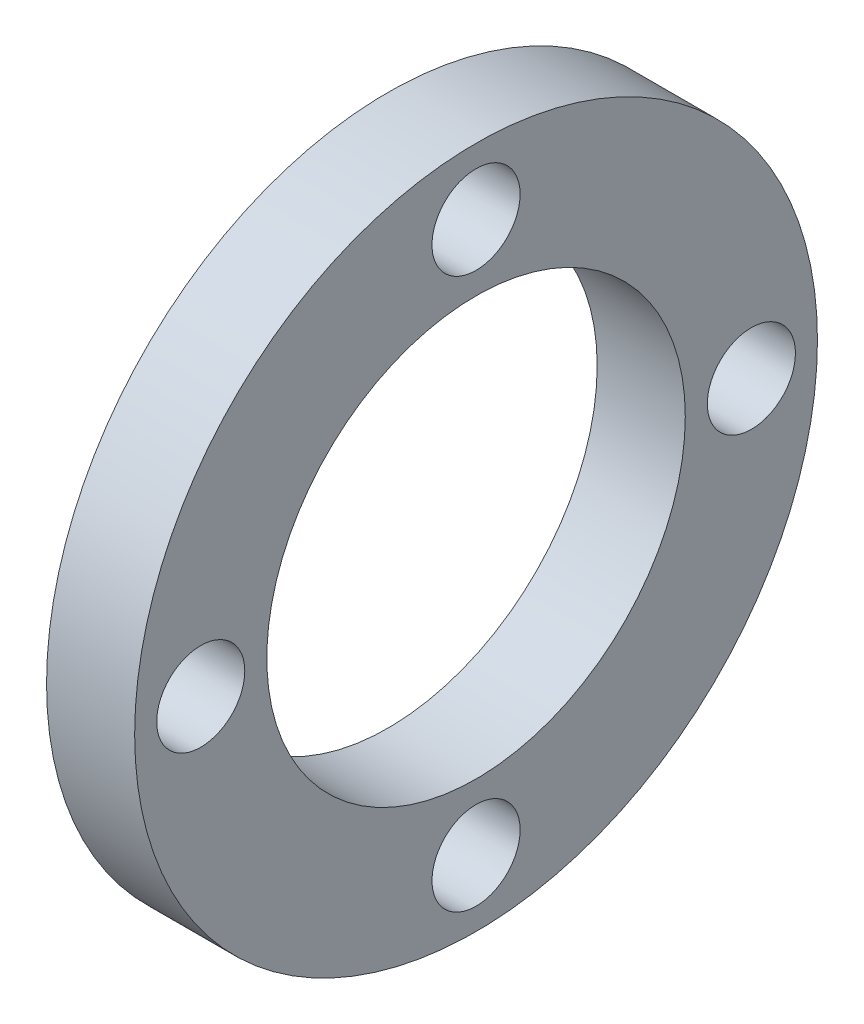
from build123d import *

# Parameters (mm, degrees)
ESQUISSE1_R        = 31
ESQUISSE1_R_2      = 19
ESQUISSE1_R_3      = 4
BOSS_EXTRU_1_DEPTH = 8


with BuildPart() as part:
    # Esquisse1 → Boss.-Extru.1 (new body)
    with BuildSketch(Plane(origin=(0, 0, 0), x_dir=(0, 0, -1), z_dir=(1, 0, 0))):
        Circle(ESQUISSE1_R)
        Circle(ESQUISSE1_R_2, mode=Mode.SUBTRACT)
        with Locations((0, 25)):
            Circle(ESQUISSE1_R_3, mode=Mode.SUBTRACT)
        with Locations((25, 0)):
            Circle(ESQUISSE1_R_3, mode=Mode.SUBTRACT)
        with Locations((0, -25)):
            Circle(ESQUISSE1_R_3, mode=Mode.SUBTRACT)
        with Locations((-25, 0)):
            Circle(ESQUISSE1_R_3, mode=Mode.SUBTRACT)
    extrude(amount=BOSS_EXTRU_1_DEPTH)


solid = part.part
